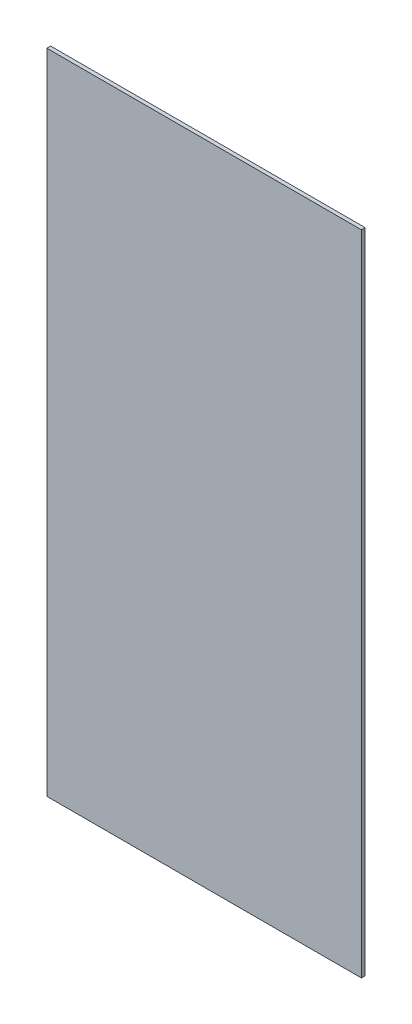
from build123d import *

# Parameters (mm, degrees)
SKICA1_W                = 252.5
SKICA1_H                = 520
P_IDAT_VYSUNUT_M1_DEPTH = 3


with BuildPart() as part:
    # Skica1 → Přidat vysunutím1 (new body)
    with BuildSketch(Plane.XY):
        Rectangle(SKICA1_W, SKICA1_H)
    extrude(amount=P_IDAT_VYSUNUT_M1_DEPTH)


solid = part.part
